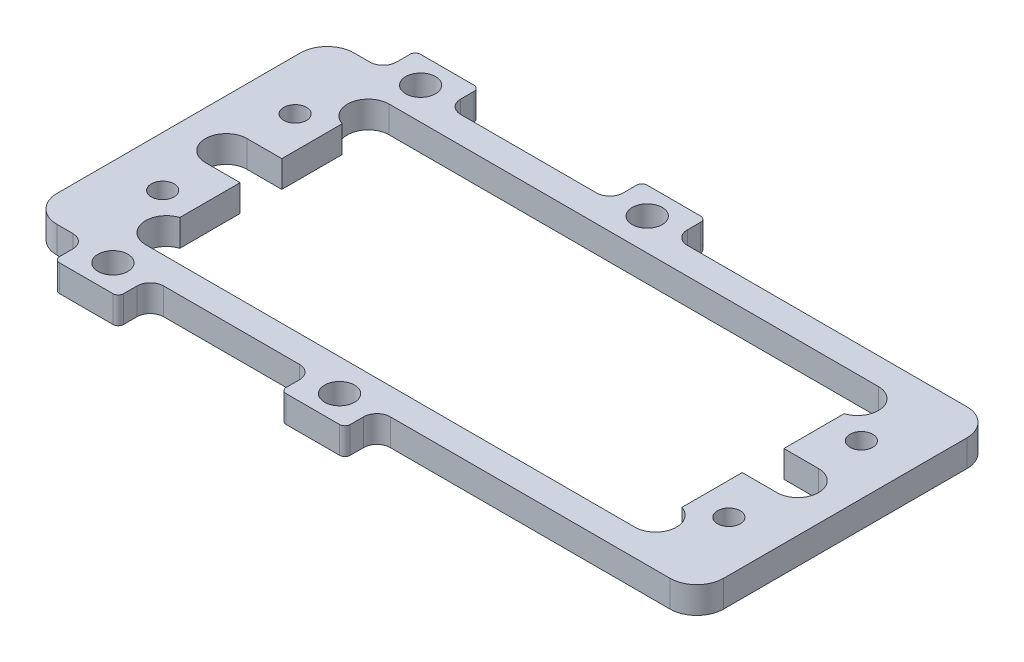
from build123d import *

# Parameters (mm, degrees)
SKETCH1_R           = 1.35255
SKETCH1_R_2         = 1.778
BOSS_EXTRUDE1_DEPTH = 3.175


with BuildPart() as part:
    # Sketch1 → Boss-Extrude1 (new body)
    with BuildSketch(Plane.XZ):
        with BuildLine():
            Line((-6.02234, -19.2405), (-6.02234, -20.828))
            ThreePointArc((-6.02234, -20.828), (-5.836352806, -21.277012806), (-5.38734, -21.463))
            Line((-5.38734, -21.463), (0.96266, -21.463))
            ThreePointArc((0.96266, -21.463), (1.411672806, -21.277012806), (1.59766, -20.828))
            Line((1.59766, -20.828), (1.59766, -19.2405))
            ThreePointArc((1.59766, -19.2405), (2.062627985, -18.117967985), (3.18516, -17.653))
            Line((3.18516, -17.653), (36.43122, -17.653))
            ThreePointArc((36.43122, -17.653), (38.688856389, -16.717856389), (39.624, -14.46022))
            Line((39.624, -14.46022), (39.624, 14.46022))
            ThreePointArc((39.624, 14.46022), (38.688856389, 16.717856389), (36.43122, 17.653))
            Line((36.43122, 17.653), (3.18516, 17.653))
            ThreePointArc((3.18516, 17.653), (2.062627985, 18.117967985), (1.59766, 19.2405))
            Line((1.59766, 19.2405), (1.59766, 20.828))
            ThreePointArc((1.59766, 20.828), (1.411672806, 21.277012806), (0.96266, 21.463))
            Line((0.96266, 21.463), (-5.38734, 21.463))
            ThreePointArc((-5.38734, 21.463), (-5.836352806, 21.277012806), (-6.02234, 20.828))
            Line((-6.02234, 20.828), (-6.02234, 19.2405))
            ThreePointArc((-6.02234, 19.2405), (-6.487307985, 18.117967985), (-7.60984, 17.653))
            Line((-7.60984, 17.653), (-23.755604, 17.653))
            ThreePointArc((-23.755604, 17.653), (-24.878136015, 18.117967985), (-25.343104, 19.2405))
            Line((-25.343104, 19.2405), (-25.343104, 20.828))
            ThreePointArc((-25.343104, 20.828), (-25.529091194, 21.277012806), (-25.978104, 21.463))
            Line((-25.978104, 21.463), (-32.328104, 21.463))
            ThreePointArc((-32.328104, 21.463), (-32.777116806, 21.277012806), (-32.963104, 20.828))
            Line((-32.963104, 20.828), (-32.963104, 19.2405))
            ThreePointArc((-32.963104, 19.2405), (-33.428071985, 18.117967985), (-34.550604, 17.653))
            Line((-34.550604, 17.653), (-36.43122, 17.653))
            ThreePointArc((-36.43122, 17.653), (-38.688856389, 16.717856389), (-39.624, 14.46022))
            Line((-39.624, 14.46022), (-39.624, -14.46022))
            ThreePointArc((-39.624, -14.46022), (-38.688856389, -16.717856389), (-36.43122, -17.653))
            Line((-36.43122, -17.653), (-34.550604, -17.653))
            ThreePointArc((-34.550604, -17.653), (-33.428071985, -18.117967985), (-32.963104, -19.2405))
            Line((-32.963104, -19.2405), (-32.963104, -20.828))
            ThreePointArc((-32.963104, -20.828), (-32.777116806, -21.277012806), (-32.328104, -21.463))
            Line((-32.328104, -21.463), (-25.978104, -21.463))
            ThreePointArc((-25.978104, -21.463), (-25.529091194, -21.277012806), (-25.343104, -20.828))
            Line((-25.343104, -20.828), (-25.343104, -19.2405))
            ThreePointArc((-25.343104, -19.2405), (-24.878136015, -18.117967985), (-23.755604, -17.653))
            Line((-23.755604, -17.653), (-7.60984, -17.653))
            ThreePointArc((-7.60984, -17.653), (-6.487307985, -18.117967985), (-6.02234, -19.2405))
        make_face()
        with Locations((33.655, -7.874)):
            Circle(SKETCH1_R, mode=Mode.SUBTRACT)
        with Locations((-33.655, 7.874)):
            Circle(SKETCH1_R, mode=Mode.SUBTRACT)
        with Locations((-33.655, -7.874)):
            Circle(SKETCH1_R, mode=Mode.SUBTRACT)
        with Locations((-2.21234, 18.288)):
            Circle(SKETCH1_R_2, mode=Mode.SUBTRACT)
        with Locations((-29.153104, -18.288)):
            Circle(SKETCH1_R_2, mode=Mode.SUBTRACT)
        with Locations((-2.21234, -18.288)):
            Circle(SKETCH1_R_2, mode=Mode.SUBTRACT)
        with Locations((-29.153104, 18.288)):
            Circle(SKETCH1_R_2, mode=Mode.SUBTRACT)
        with Locations((33.655, 7.874)):
            Circle(SKETCH1_R, mode=Mode.SUBTRACT)
        with BuildLine():
            Line((-33.9725, 2.4765), (-29.845, 2.4765))
            Line((-29.845, 2.4765), (-29.845, 9.645968035))
            ThreePointArc((-29.845, 9.645968035), (-31.52653105, 12.388525412), (-29.08046, 14.478))
            Line((-29.08046, 14.478), (29.08046, 14.478))
            ThreePointArc((29.08046, 14.478), (31.52653105, 12.388525412), (29.845, 9.645968035))
            Line((29.845, 9.645968035), (29.845, 2.4765))
            Line((29.845, 2.4765), (33.9725, 2.4765))
            ThreePointArc((33.9725, 2.4765), (36.449, 0), (33.9725, -2.4765))
            Line((33.9725, -2.4765), (29.845, -2.4765))
            Line((29.845, -2.4765), (29.845, -9.645968035))
            ThreePointArc((29.845, -9.645968035), (31.52653105, -12.388525412), (29.08046, -14.478))
            Line((29.08046, -14.478), (-29.08046, -14.478))
            ThreePointArc((-29.08046, -14.478), (-31.52653105, -12.388525412), (-29.845, -9.645968035))
            Line((-29.845, -9.645968035), (-29.845, -2.4765))
            Line((-29.845, -2.4765), (-33.9725, -2.4765))
            ThreePointArc((-33.9725, -2.4765), (-36.449, 0), (-33.9725, 2.4765))
        make_face(mode=Mode.SUBTRACT)
    extrude(amount=-BOSS_EXTRUDE1_DEPTH)


solid = part.part
